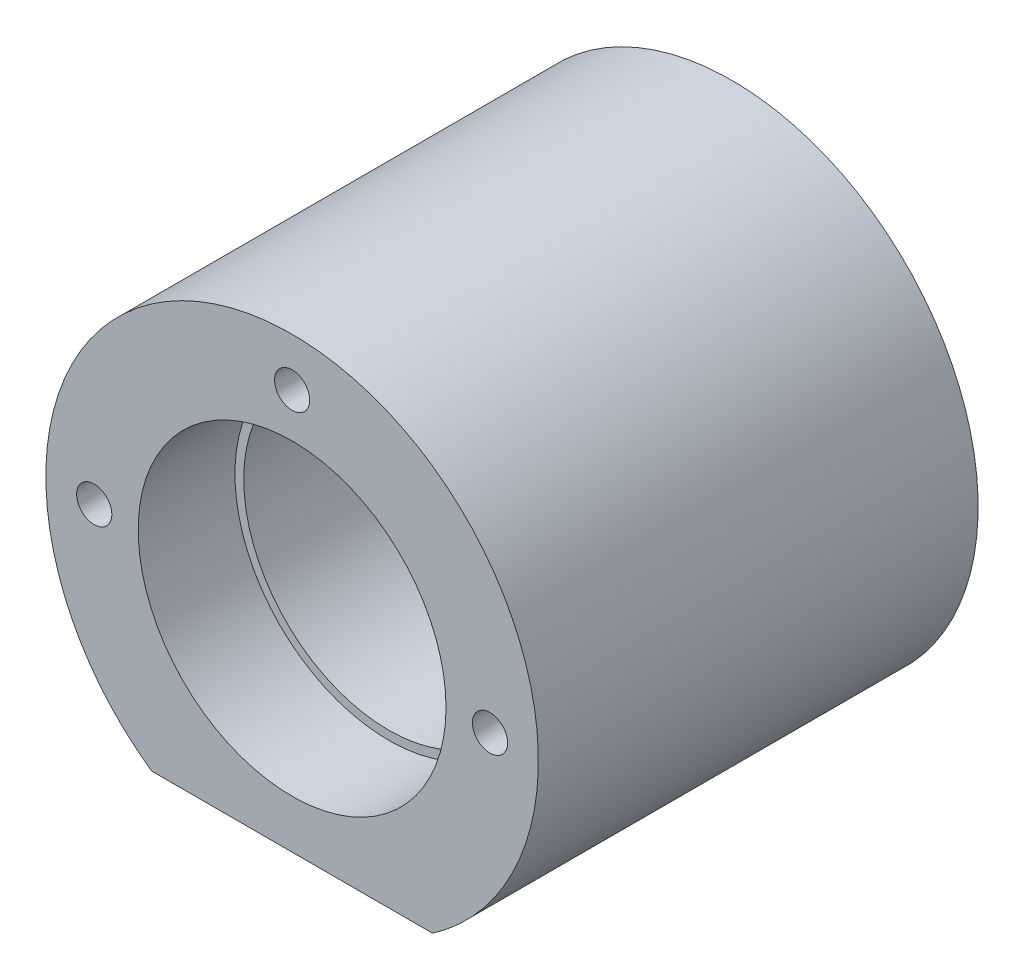
from build123d import *

# Parameters (mm, degrees)
SKETCH1_R           = 16.5
BOSS_EXTRUDE1_DEPTH = 50
SKETCH2_R           = 17.5
CUT_EXTRUDE1_DEPTH  = 11
SKETCH3_R           = 2
CUT_EXTRUDE2_DEPTH  = 10


with BuildPart() as part:
    # Sketch1 → Boss-Extrude1 (new body)
    with BuildSketch(Plane.XY):
        with BuildLine():
            Line((-15.968719423, 0), (15.968719423, 0))
            ThreePointArc((15.968719423, 0), (0, 51), (-15.968719423, 0))
        make_face()
        with Locations((0, 23)):
            Circle(SKETCH1_R, mode=Mode.SUBTRACT)
    extrude(amount=BOSS_EXTRUDE1_DEPTH)

    # Sketch2 → Cut-Extrude1 (cut)
    with BuildSketch(Plane.XY.offset(50)):
        with Locations((0, 23)):
            Circle(SKETCH2_R)
    cut_extrude1 = extrude(amount=-CUT_EXTRUDE1_DEPTH, mode=Mode.SUBTRACT)

    # Mirror1: Cut-Extrude1 across plane
    add(cut_extrude1.mirror(Plane.XY.offset(25)), mode=Mode.SUBTRACT)

    # Sketch3 → Cut-Extrude2 (cut)
    with BuildSketch(Plane(origin=(0, 0, 0), x_dir=(-1, 0, 0), z_dir=(0, 0, -1))):
        with Locations((0, 45.5)):
            Circle(SKETCH3_R)
        with Locations((-22.5, 23)):
            Circle(SKETCH3_R)
        with Locations((22.5, 23)):
            Circle(SKETCH3_R)
    cut_extrude2 = extrude(amount=-CUT_EXTRUDE2_DEPTH, mode=Mode.SUBTRACT)

    # Mirror2: Cut-Extrude2 across plane
    add(cut_extrude2.mirror(Plane.XY.offset(25)), mode=Mode.SUBTRACT)


solid = part.part
